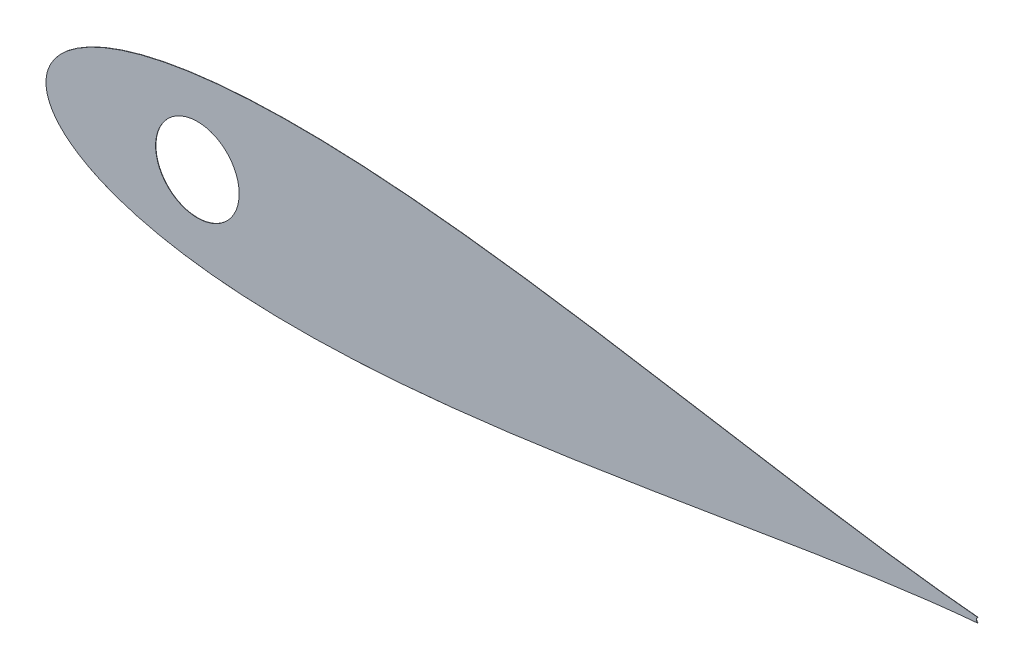
from build123d import *

# Parameters (mm, degrees)
SKETCH2_R           = 17.272
BOSS_EXTRUDE1_DEPTH = 0.127


with BuildPart() as part:
    # Sketch2 → Boss-Extrude1 (new body)
    with BuildSketch(Plane.XY):
        with BuildLine():
            ThreePointArc((733.094458589, 571.145233343), (732.545217897, 570.114105972), (733.092625489, 569.082004271))
            add(Edge.make_bspline(
                [(733.094458589, 571.145233343), (731.071708037, 571.317921944), (726.773768323, 571.715269774), (719.930993216, 572.427098506), (712.334872672, 573.301658873), (704.022402008, 574.343315633), (695.032362487, 575.553129378), (685.403631288, 576.928387748), (675.177904294, 578.461986944), (664.398604914, 580.143017226), (653.110892108, 581.956469163), (641.361413459, 583.883612287), (629.198169585, 585.902229126), (616.670358597, 587.98684052), (603.828293671, 590.10916185), (590.723320288, 592.238442601), (577.407772952, 594.341970434), (563.934946828, 596.385512076), (550.35909561, 598.333920975), (536.735425172, 600.151583235), (523.120106966, 601.803052389), (509.570287351, 603.253558862), (496.144096325, 604.469623955), (482.900641975, 605.419548215), (469.900009328, 606.074004196), (457.203247278, 606.406588245), (444.872347821, 606.39424081), (432.970266907, 606.017374444), (421.560925424, 605.261233674), (410.709394946, 604.114853717), (400.482000776, 602.573067108), (390.946941922, 600.635333008), (382.174754121, 598.308135436), (374.239597628, 595.605113532), (367.220633365, 592.550351675), (361.203098109, 589.184301712), (356.276891114, 585.575270729), (352.524964086, 581.841134841), (349.984849518, 578.179330061), (348.568410846, 574.875654104), (347.996426137, 572.225488819), (347.866151466, 570.113697054), (347.996426137, 568.001905288), (348.568410846, 565.351740003), (349.984849518, 562.048064047), (352.524964086, 558.386259267), (356.276891114, 554.652123378), (361.203098109, 551.043092395), (367.220633365, 547.677042433), (374.239597628, 544.622280575), (382.174754121, 541.919258671), (390.946941922, 539.5920611), (400.482000776, 537.654326999), (410.709394946, 536.11254039), (421.560925424, 534.966160433), (432.970266907, 534.210019663), (444.872347821, 533.833153298), (457.203247278, 533.820805862), (469.900009328, 534.153389912), (482.900641975, 534.807845892), (496.144096325, 535.757770153), (509.570287351, 536.973835246), (523.120106966, 538.424341719), (536.735425172, 540.075810873), (550.35909561, 541.893473132), (563.934946828, 543.841882032), (577.407772952, 545.885423673), (590.723320288, 547.988951506), (603.828293671, 550.118232257), (616.670358597, 552.240553587), (629.198169585, 554.325164982), (641.361413459, 556.343781821), (653.110892108, 558.270924944), (664.398604914, 560.084376881), (675.177904294, 561.765407163), (685.403631288, 563.299006359), (695.032362487, 564.674264729), (704.022402008, 565.884078475), (712.334872672, 566.925735235), (719.930993216, 567.800295602), (726.773159483, 568.512060998), (731.070491643, 568.909359706), (733.092625489, 569.082004271)],
                knots=[0.021301255, 0.021301255, 0.021301255, 0.021301255, 0.028552555, 0.036780684, 0.045920102, 0.055931764, 0.066772884, 0.07839713, 0.090754827, 0.103793165, 0.117456432, 0.131686226, 0.146421738, 0.161599998, 0.177156133, 0.193023668, 0.209134786, 0.225420633, 0.241811602, 0.258237647, 0.274628557, 0.290914287, 0.307025229, 0.322892517, 0.338448342, 0.353626207, 0.368361232, 0.382590428, 0.396252961, 0.409290412, 0.42164701, 0.433269881, 0.444109249, 0.45411864, 0.463255055, 0.471479114, 0.478755289, 0.485052318, 0.490344026, 0.494609833, 0.497833231, 0.5, 0.502166769, 0.505390167, 0.509655974, 0.514947682, 0.521244711, 0.528520886, 0.536744945, 0.54588136, 0.555890751, 0.566730119, 0.57835299, 0.590709588, 0.603747039, 0.617409572, 0.631638768, 0.646373793, 0.661551658, 0.677107483, 0.692974771, 0.709085713, 0.725371443, 0.741762353, 0.758188398, 0.774579367, 0.790865214, 0.806976332, 0.822843867, 0.838400002, 0.853578262, 0.868313774, 0.882543568, 0.896206835, 0.909245173, 0.92160287, 0.933227116, 0.944068236, 0.954079898, 0.963219316, 0.971447445, 0.978696555, 0.978696555, 0.978696555, 0.978696555], degree=3))
        make_face()
        with Locations((410.491644578, 570.113697058)):
            Circle(SKETCH2_R, mode=Mode.SUBTRACT)
    extrude(amount=BOSS_EXTRUDE1_DEPTH)


solid = part.part
